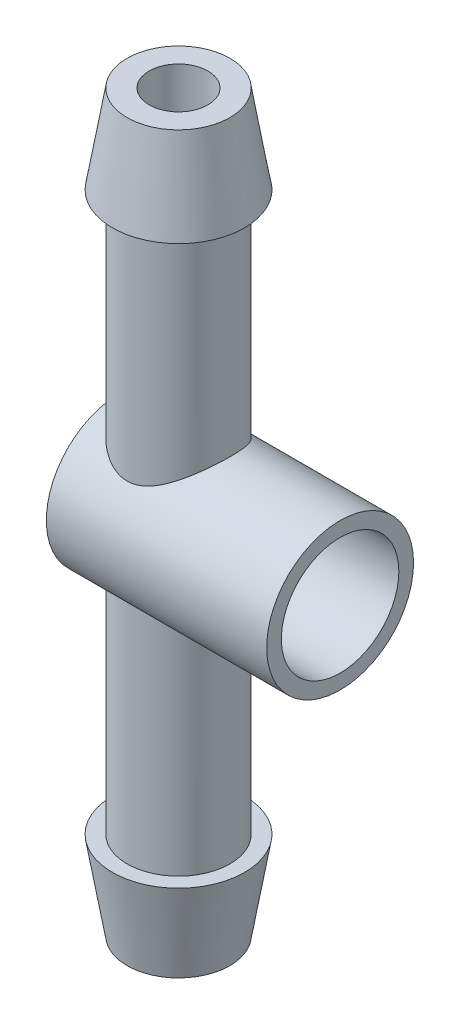
from build123d import *

# Parameters (mm, degrees)
SKETCH3_W           = 2.5
SKETCH3_H           = 25
SKETCH3_H_2         = 6.220476857
SKETCH3_H_3         = 18.779523143
BOSS_EXTRUDE2_START = 3.5
SKETCH5_R           = 5
BOSS_EXTRUDE2_DEPTH = 7.5
SKETCH6_R           = 4
CUT_EXTRUDE1_DEPTH  = 13.5
SKETCH7_R           = 2
CUT_EXTRUDE2_DEPTH  = 50


with BuildPart() as part:
    # Sketch3 → Revolve1 (revolve)
    with BuildSketch(Plane.XY):
        Polygon((2.5, 6.220476857), (2.5, 0), (3.5, 0), (3.5, 19), (4.5, 19), (3.5, 25), (2.5, 25), align=None)
        Polygon((2.5, 0), (2.5, -25), (3.5, -25), (4.5, -19), (3.5, -19), (3.5, 0), align=None)
        with Locations((1.25, -12.5)):
            Rectangle(SKETCH3_W, SKETCH3_H)
        with Locations((1.25, 3.110238429)):
            Rectangle(SKETCH3_W, SKETCH3_H_2)
        with Locations((1.25, 15.610238429)):
            Rectangle(SKETCH3_W, SKETCH3_H_3)
    revolve(axis=Axis((0, 0, 0), (0, 1, 0)))

    # Sketch5 → Boss-Extrude2 (add, symmetric)
    with BuildSketch(Plane(origin=(0, 0, 0), x_dir=(0, 0, -1), z_dir=(1, 0, 0)).offset(BOSS_EXTRUDE2_START)):
        Circle(SKETCH5_R)
    extrude(amount=BOSS_EXTRUDE2_DEPTH, both=True)

    # Sketch6 → Cut-Extrude1 (cut)
    with BuildSketch(Plane(origin=(11, 0, 0), x_dir=(0, 0, -1), z_dir=(1, 0, 0))):
        Circle(SKETCH6_R)
    extrude(amount=-CUT_EXTRUDE1_DEPTH, mode=Mode.SUBTRACT)

    # Sketch7 → Cut-Extrude2 (cut)
    with BuildSketch(Plane.XZ.offset(25)):
        Circle(SKETCH7_R)
    extrude(amount=-CUT_EXTRUDE2_DEPTH, mode=Mode.SUBTRACT)


solid = part.part
